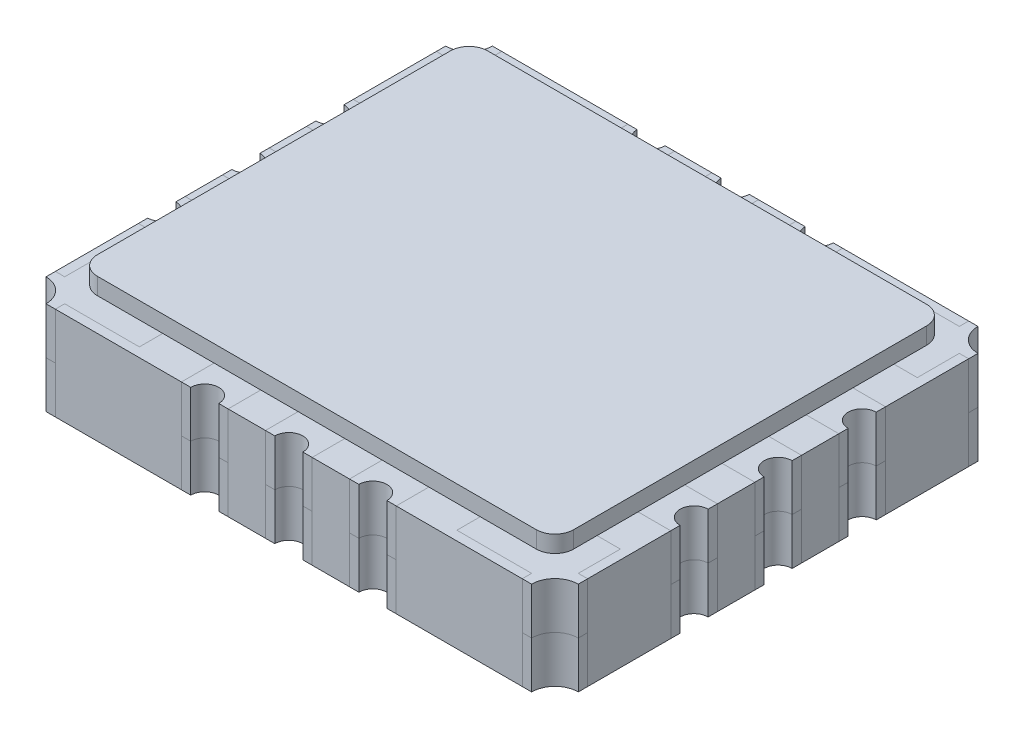
from build123d import *

# Parameters (mm, degrees)
EXTRUDE_7_DEPTH     = 0.5
EXTRUDE_7_2_DEPTH   = 0.5
EXTRUDE_7_3_DEPTH   = 0.5
EXTRUDE_7_4_DEPTH   = 0.5
EXTRUDE_7_5_DEPTH   = 0.5
EXTRUDE_7_6_DEPTH   = 0.5
EXTRUDE_7_7_DEPTH   = 0.5
EXTRUDE_7_8_DEPTH   = 0.5
EXTRUDE_7_9_DEPTH   = 0.5
EXTRUDE_7_10_DEPTH  = 0.5
EXTRUDE_7_11_DEPTH  = 0.5
EXTRUDE_7_12_DEPTH  = 0.5
EXTRUDE_7_13_DEPTH  = 0.5
EXTRUDE_7_14_DEPTH  = 0.5
EXTRUDE_7_15_DEPTH  = 0.5
EXTRUDE_7_16_DEPTH  = 0.5
EXTRUDE_7_17_DEPTH  = 0.5
EXTRUDE_10_DEPTH    = 1
EXTRUDE_START       = 0.5
EXTRUDE_11_DEPTH    = 0.5
EXTRUDE_11_2_DEPTH  = 0.5
EXTRUDE_11_3_DEPTH  = 0.5
EXTRUDE_11_4_DEPTH  = 0.5
EXTRUDE_11_5_DEPTH  = 0.5
EXTRUDE_11_6_DEPTH  = 0.5
EXTRUDE_11_7_DEPTH  = 0.5
EXTRUDE_11_8_DEPTH  = 0.5
EXTRUDE_11_9_DEPTH  = 0.5
EXTRUDE_11_10_DEPTH = 0.5
EXTRUDE_11_11_DEPTH = 0.5
EXTRUDE_11_12_DEPTH = 0.5
EXTRUDE_11_13_DEPTH = 0.5
EXTRUDE_11_14_DEPTH = 0.5
EXTRUDE_11_15_DEPTH = 0.5
EXTRUDE_11_16_DEPTH = 0.5
EXTRUDE_11_17_DEPTH = 0.5
EXTRUDE_13_DEPTH    = 1.18


with BuildPart() as part:
    # Эскиз1 → Бобышка-Вытянуть7 (new body)
    with BuildSketch(Plane(origin=(0, 0, 0), x_dir=(1, 0, 0), z_dir=(0, 1, 0))):
        with BuildLine():
            Line((-2.5, 2.39), (-2.6, 2.39))
            ThreePointArc((-2.6, 2.39), (-2.673223305, 2.213223305), (-2.85, 2.14))
            Line((-2.85, 2.14), (-2.85, 2.04))
            Line((-2.85, 2.04), (-2.75, 2.04))
            Line((-2.75, 2.04), (-2.75, 1.59))
            Line((-2.75, 1.59), (-1.7, 1.59))
            Line((-1.7, 1.59), (-1.7, 2.29))
            Line((-1.7, 2.29), (-2.5, 2.29))
            Line((-2.5, 2.29), (-2.5, 2.39))
        make_face()
    extrude(amount=EXTRUDE_7_DEPTH)


with BuildPart() as body_2:
    # Эскиз1 → Extrude 7 2 (new body)
    with BuildSketch(Plane(origin=(0, 0, 0), x_dir=(1, 0, 0), z_dir=(0, 1, 0))):
        with BuildLine():
            Line((-1.05, 2.39), (-1.15, 2.39))
            Line((-1.15, 2.39), (-1.15, 1.39))
            Line((-1.15, 1.39), (-0.65, 1.39))
            Line((-0.65, 1.39), (-0.65, 2.39))
            Line((-0.65, 2.39), (-0.75, 2.39))
            ThreePointArc((-0.75, 2.39), (-0.9, 2.24), (-1.05, 2.39))
        make_face()
    extrude(amount=EXTRUDE_7_2_DEPTH)


with BuildPart() as body_3:
    # Эскиз1 → Extrude 7 3 (new body)
    with BuildSketch(Plane(origin=(0, 0, 0), x_dir=(1, 0, 0), z_dir=(0, 1, 0))):
        with BuildLine():
            Line((-2.85, 1.15), (-2.85, 1.05))
            ThreePointArc((-2.85, 1.05), (-2.7, 0.9), (-2.85, 0.75))
            Line((-2.85, 0.75), (-2.85, 0.65))
            Line((-2.85, 0.65), (-1.85, 0.65))
            Line((-1.85, 0.65), (-1.85, 1.15))
            Line((-1.85, 1.15), (-2.85, 1.15))
        make_face()
    extrude(amount=EXTRUDE_7_3_DEPTH)


with BuildPart() as body_4:
    # Эскиз1 → Extrude 7 4 (new body)
    with BuildSketch(Plane(origin=(0, 0, 0), x_dir=(1, 0, 0), z_dir=(0, 1, 0))):
        with BuildLine():
            Line((0.25, 1.39), (0.25, 2.39))
            Line((0.25, 2.39), (0.15, 2.39))
            ThreePointArc((0.15, 2.39), (0, 2.24), (-0.15, 2.39))
            Line((-0.15, 2.39), (-0.25, 2.39))
            Line((-0.25, 2.39), (-0.25, 1.39))
            Line((-0.25, 1.39), (0.25, 1.39))
        make_face()
    extrude(amount=EXTRUDE_7_4_DEPTH)


with BuildPart() as body_5:
    # Эскиз1 → Extrude 7 5 (new body)
    with BuildSketch(Plane(origin=(0, 0, 0), x_dir=(1, 0, 0), z_dir=(0, 1, 0))):
        with BuildLine():
            Line((-2.85, -0.25), (-1.85, -0.25))
            Line((-1.85, -0.25), (-1.85, 0.25))
            Line((-1.85, 0.25), (-2.85, 0.25))
            Line((-2.85, 0.25), (-2.85, 0.15))
            ThreePointArc((-2.85, 0.15), (-2.7, 0), (-2.85, -0.15))
            Line((-2.85, -0.15), (-2.85, -0.25))
        make_face()
    extrude(amount=EXTRUDE_7_5_DEPTH)


with BuildPart() as body_6:
    # Эскиз1 → Extrude 7 6 (new body)
    with BuildSketch(Plane(origin=(0, 0, 0), x_dir=(1, 0, 0), z_dir=(0, 1, 0))):
        with BuildLine():
            Line((1.15, 1.39), (1.15, 2.39))
            Line((1.15, 2.39), (1.05, 2.39))
            ThreePointArc((1.05, 2.39), (0.9, 2.24), (0.75, 2.39))
            Line((0.75, 2.39), (0.65, 2.39))
            Line((0.65, 2.39), (0.65, 1.39))
            Line((0.65, 1.39), (1.15, 1.39))
        make_face()
    extrude(amount=EXTRUDE_7_6_DEPTH)


with BuildPart() as body_7:
    # Эскиз1 → Extrude 7 7 (new body)
    with BuildSketch(Plane(origin=(0, 0, 0), x_dir=(1, 0, 0), z_dir=(0, 1, 0))):
        with BuildLine():
            Line((-2.85, -1.15), (-1.85, -1.15))
            Line((-1.85, -1.15), (-1.85, -0.65))
            Line((-1.85, -0.65), (-2.85, -0.65))
            Line((-2.85, -0.65), (-2.85, -0.75))
            ThreePointArc((-2.85, -0.75), (-2.7, -0.9), (-2.85, -1.05))
            Line((-2.85, -1.05), (-2.85, -1.15))
        make_face()
    extrude(amount=EXTRUDE_7_7_DEPTH)


with BuildPart() as body_8:
    # Эскиз1 → Extrude 7 8 (new body)
    with BuildSketch(Plane(origin=(0, 0, 0), x_dir=(1, 0, 0), z_dir=(0, 1, 0))):
        with BuildLine():
            Line((1.7, 1.59), (2.75, 1.59))
            Line((2.75, 1.59), (2.75, 2.04))
            Line((2.75, 2.04), (2.85, 2.04))
            Line((2.85, 2.04), (2.85, 2.14))
            ThreePointArc((2.85, 2.14), (2.673223305, 2.213223305), (2.6, 2.39))
            Line((2.6, 2.39), (2.5, 2.39))
            Line((2.5, 2.39), (2.5, 2.29))
            Line((2.5, 2.29), (1.7, 2.29))
            Line((1.7, 2.29), (1.7, 1.59))
        make_face()
    extrude(amount=EXTRUDE_7_8_DEPTH)


with BuildPart() as body_9:
    # Эскиз1 → Extrude 7 9 (new body)
    with BuildSketch(Plane(origin=(0, 0, 0), x_dir=(1, 0, 0), z_dir=(0, 1, 0))):
        with BuildLine():
            Line((-1.7, -2.29), (-1.7, -1.59))
            Line((-1.7, -1.59), (-2.75, -1.59))
            Line((-2.75, -1.59), (-2.75, -2.04))
            Line((-2.75, -2.04), (-2.85, -2.04))
            Line((-2.85, -2.04), (-2.85, -2.14))
            ThreePointArc((-2.85, -2.14), (-2.673223305, -2.213223305), (-2.6, -2.39))
            Line((-2.6, -2.39), (-2.5, -2.39))
            Line((-2.5, -2.39), (-2.5, -2.29))
            Line((-2.5, -2.29), (-1.7, -2.29))
        make_face()
    extrude(amount=EXTRUDE_7_9_DEPTH)


with BuildPart() as body_10:
    # Эскиз1 → Extrude 7 10 (new body)
    with BuildSketch(Plane(origin=(0, 0, 0), x_dir=(1, 0, 0), z_dir=(0, 1, 0))):
        with BuildLine():
            Line((1.85, 0.65), (2.85, 0.65))
            Line((2.85, 0.65), (2.85, 0.75))
            ThreePointArc((2.85, 0.75), (2.7, 0.9), (2.85, 1.05))
            Line((2.85, 1.05), (2.85, 1.15))
            Line((2.85, 1.15), (1.85, 1.15))
            Line((1.85, 1.15), (1.85, 0.65))
        make_face()
    extrude(amount=EXTRUDE_7_10_DEPTH)


with BuildPart() as body_11:
    # Эскиз1 → Extrude 7 11 (new body)
    with BuildSketch(Plane(origin=(0, 0, 0), x_dir=(1, 0, 0), z_dir=(0, 1, 0))):
        with BuildLine():
            Line((-0.65, -2.39), (-0.65, -1.39))
            Line((-0.65, -1.39), (-1.15, -1.39))
            Line((-1.15, -1.39), (-1.15, -2.39))
            Line((-1.15, -2.39), (-1.05, -2.39))
            ThreePointArc((-1.05, -2.39), (-0.9, -2.24), (-0.75, -2.39))
            Line((-0.75, -2.39), (-0.65, -2.39))
        make_face()
    extrude(amount=EXTRUDE_7_11_DEPTH)


with BuildPart() as body_12:
    # Эскиз1 → Extrude 7 12 (new body)
    with BuildSketch(Plane(origin=(0, 0, 0), x_dir=(1, 0, 0), z_dir=(0, 1, 0))):
        with BuildLine():
            Line((1.85, -0.25), (2.85, -0.25))
            Line((2.85, -0.25), (2.85, -0.15))
            ThreePointArc((2.85, -0.15), (2.7, 0), (2.85, 0.15))
            Line((2.85, 0.15), (2.85, 0.25))
            Line((2.85, 0.25), (1.85, 0.25))
            Line((1.85, 0.25), (1.85, -0.25))
        make_face()
    extrude(amount=EXTRUDE_7_12_DEPTH)


with BuildPart() as body_13:
    # Эскиз1 → Extrude 7 13 (new body)
    with BuildSketch(Plane(origin=(0, 0, 0), x_dir=(1, 0, 0), z_dir=(0, 1, 0))):
        with BuildLine():
            Line((0.25, -2.39), (0.25, -1.39))
            Line((0.25, -1.39), (-0.25, -1.39))
            Line((-0.25, -1.39), (-0.25, -2.39))
            Line((-0.25, -2.39), (-0.15, -2.39))
            ThreePointArc((-0.15, -2.39), (0, -2.24), (0.15, -2.39))
            Line((0.15, -2.39), (0.25, -2.39))
        make_face()
    extrude(amount=EXTRUDE_7_13_DEPTH)


with BuildPart() as body_14:
    # Эскиз1 → Extrude 7 14 (new body)
    with BuildSketch(Plane(origin=(0, 0, 0), x_dir=(1, 0, 0), z_dir=(0, 1, 0))):
        with BuildLine():
            Line((1.85, -1.15), (2.85, -1.15))
            Line((2.85, -1.15), (2.85, -1.05))
            ThreePointArc((2.85, -1.05), (2.7, -0.9), (2.85, -0.75))
            Line((2.85, -0.75), (2.85, -0.65))
            Line((2.85, -0.65), (1.85, -0.65))
            Line((1.85, -0.65), (1.85, -1.15))
        make_face()
    extrude(amount=EXTRUDE_7_14_DEPTH)


with BuildPart() as body_15:
    # Эскиз1 → Extrude 7 15 (new body)
    with BuildSketch(Plane(origin=(0, 0, 0), x_dir=(1, 0, 0), z_dir=(0, 1, 0))):
        with BuildLine():
            Line((1.15, -2.39), (1.15, -1.39))
            Line((1.15, -1.39), (0.65, -1.39))
            Line((0.65, -1.39), (0.65, -2.39))
            Line((0.65, -2.39), (0.75, -2.39))
            ThreePointArc((0.75, -2.39), (0.9, -2.24), (1.05, -2.39))
            Line((1.05, -2.39), (1.15, -2.39))
        make_face()
    extrude(amount=EXTRUDE_7_15_DEPTH)


with BuildPart() as body_16:
    # Эскиз1 → Extrude 7 16 (new body)
    with BuildSketch(Plane(origin=(0, 0, 0), x_dir=(1, 0, 0), z_dir=(0, 1, 0))):
        with BuildLine():
            Line((1.7, -1.59), (1.7, -2.29))
            Line((1.7, -2.29), (2.5, -2.29))
            Line((2.5, -2.29), (2.5, -2.39))
            Line((2.5, -2.39), (2.6, -2.39))
            ThreePointArc((2.6, -2.39), (2.673223305, -2.213223305), (2.85, -2.14))
            Line((2.85, -2.14), (2.85, -2.04))
            Line((2.85, -2.04), (2.75, -2.04))
            Line((2.75, -2.04), (2.75, -1.59))
            Line((2.75, -1.59), (1.7, -1.59))
        make_face()
    extrude(amount=EXTRUDE_7_16_DEPTH)


with BuildPart() as body_17:
    # Эскиз1 → Extrude 7 17 (new body)
    with BuildSketch(Plane(origin=(0, 0, 0), x_dir=(1, 0, 0), z_dir=(0, 1, 0))):
        Polygon((-0.722867966, 0.935), (-0.935, 0.722867966), (-0.935, -0.935), (0.935, -0.935), (0.935, 0.935), align=None)
    extrude(amount=EXTRUDE_7_17_DEPTH)


with BuildPart() as body_18:
    # Эскиз1<13> → Бобышка-Вытянуть10 (new body)
    with BuildSketch(Plane(origin=(0, 0, 0), x_dir=(1, 0, 0), z_dir=(0, 1, 0))):
        Polygon((-1.15, 2.39), (-2.5, 2.39), (-2.5, 2.29), (-1.7, 2.29), (-1.7, 1.59), (-2.75, 1.59), (-2.75, 2.04), (-2.85, 2.04), (-2.85, 1.15), (-1.85, 1.15), (-1.85, 0.65), (-2.85, 0.65), (-2.85, 0.25), (-1.85, 0.25), (-1.85, -0.25), (-2.85, -0.25), (-2.85, -0.65), (-1.85, -0.65), (-1.85, -1.15), (-2.85, -1.15), (-2.85, -2.04), (-2.75, -2.04), (-2.75, -1.59), (-1.7, -1.59), (-1.7, -2.29), (-2.5, -2.29), (-2.5, -2.39), (-1.15, -2.39), (-1.15, -1.39), (-0.65, -1.39), (-0.65, -2.39), (-0.25, -2.39), (-0.25, -1.39), (0.25, -1.39), (0.25, -2.39), (0.65, -2.39), (0.65, -1.39), (1.15, -1.39), (1.15, -2.39), (2.5, -2.39), (2.5, -2.29), (1.7, -2.29), (1.7, -1.59), (2.75, -1.59), (2.75, -2.04), (2.85, -2.04), (2.85, -1.15), (1.85, -1.15), (1.85, -0.65), (2.85, -0.65), (2.85, -0.25), (1.85, -0.25), (1.85, 0.25), (2.85, 0.25), (2.85, 0.65), (1.85, 0.65), (1.85, 1.15), (2.85, 1.15), (2.85, 2.04), (2.75, 2.04), (2.75, 1.59), (1.7, 1.59), (1.7, 2.29), (2.5, 2.29), (2.5, 2.39), (1.15, 2.39), (1.15, 1.39), (0.65, 1.39), (0.65, 2.39), (0.25, 2.39), (0.25, 1.39), (-0.25, 1.39), (-0.25, 2.39), (-0.65, 2.39), (-0.65, 1.39), (-1.15, 1.39), align=None)
        Polygon((-0.935, 0.722867966), (-0.722867966, 0.935), (0.935, 0.935), (0.935, -0.935), (-0.935, -0.935), align=None, mode=Mode.SUBTRACT)
    extrude(amount=EXTRUDE_10_DEPTH)


with BuildPart() as body_19:
    # Эскиз1<14> → Бобышка-Вытянуть11 (new body)
    with BuildSketch(Plane(origin=(0, 0, 0), x_dir=(1, 0, 0), z_dir=(0, 1, 0)).offset(EXTRUDE_START)):
        with BuildLine():
            Line((-2.5, 2.39), (-2.6, 2.39))
            ThreePointArc((-2.6, 2.39), (-2.673223305, 2.213223305), (-2.85, 2.14))
            Line((-2.85, 2.14), (-2.85, 2.04))
            Line((-2.85, 2.04), (-2.75, 2.04))
            Line((-2.75, 2.04), (-2.75, 1.59))
            Line((-2.75, 1.59), (-1.7, 1.59))
            Line((-1.7, 1.59), (-1.7, 2.29))
            Line((-1.7, 2.29), (-2.5, 2.29))
            Line((-2.5, 2.29), (-2.5, 2.39))
        make_face()
    extrude(amount=EXTRUDE_11_DEPTH)


with BuildPart() as body_20:
    # Эскиз1<14> → Extrude 11 2 (new body)
    with BuildSketch(Plane(origin=(0, 0, 0), x_dir=(1, 0, 0), z_dir=(0, 1, 0)).offset(EXTRUDE_START)):
        with BuildLine():
            Line((-1.05, 2.39), (-1.15, 2.39))
            Line((-1.15, 2.39), (-1.15, 1.39))
            Line((-1.15, 1.39), (-0.65, 1.39))
            Line((-0.65, 1.39), (-0.65, 2.39))
            Line((-0.65, 2.39), (-0.75, 2.39))
            ThreePointArc((-0.75, 2.39), (-0.9, 2.24), (-1.05, 2.39))
        make_face()
    extrude(amount=EXTRUDE_11_2_DEPTH)


with BuildPart() as body_21:
    # Эскиз1<14> → Extrude 11 3 (new body)
    with BuildSketch(Plane(origin=(0, 0, 0), x_dir=(1, 0, 0), z_dir=(0, 1, 0)).offset(EXTRUDE_START)):
        with BuildLine():
            Line((-2.85, 1.15), (-2.85, 1.05))
            ThreePointArc((-2.85, 1.05), (-2.7, 0.9), (-2.85, 0.75))
            Line((-2.85, 0.75), (-2.85, 0.65))
            Line((-2.85, 0.65), (-1.85, 0.65))
            Line((-1.85, 0.65), (-1.85, 1.15))
            Line((-1.85, 1.15), (-2.85, 1.15))
        make_face()
    extrude(amount=EXTRUDE_11_3_DEPTH)


with BuildPart() as body_22:
    # Эскиз1<14> → Extrude 11 4 (new body)
    with BuildSketch(Plane(origin=(0, 0, 0), x_dir=(1, 0, 0), z_dir=(0, 1, 0)).offset(EXTRUDE_START)):
        with BuildLine():
            Line((0.25, 1.39), (0.25, 2.39))
            Line((0.25, 2.39), (0.15, 2.39))
            ThreePointArc((0.15, 2.39), (0, 2.24), (-0.15, 2.39))
            Line((-0.15, 2.39), (-0.25, 2.39))
            Line((-0.25, 2.39), (-0.25, 1.39))
            Line((-0.25, 1.39), (0.25, 1.39))
        make_face()
    extrude(amount=EXTRUDE_11_4_DEPTH)


with BuildPart() as body_23:
    # Эскиз1<14> → Extrude 11 5 (new body)
    with BuildSketch(Plane(origin=(0, 0, 0), x_dir=(1, 0, 0), z_dir=(0, 1, 0)).offset(EXTRUDE_START)):
        with BuildLine():
            Line((-2.85, -0.25), (-1.85, -0.25))
            Line((-1.85, -0.25), (-1.85, 0.25))
            Line((-1.85, 0.25), (-2.85, 0.25))
            Line((-2.85, 0.25), (-2.85, 0.15))
            ThreePointArc((-2.85, 0.15), (-2.7, 0), (-2.85, -0.15))
            Line((-2.85, -0.15), (-2.85, -0.25))
        make_face()
    extrude(amount=EXTRUDE_11_5_DEPTH)


with BuildPart() as body_24:
    # Эскиз1<14> → Extrude 11 6 (new body)
    with BuildSketch(Plane(origin=(0, 0, 0), x_dir=(1, 0, 0), z_dir=(0, 1, 0)).offset(EXTRUDE_START)):
        with BuildLine():
            Line((1.15, 1.39), (1.15, 2.39))
            Line((1.15, 2.39), (1.05, 2.39))
            ThreePointArc((1.05, 2.39), (0.9, 2.24), (0.75, 2.39))
            Line((0.75, 2.39), (0.65, 2.39))
            Line((0.65, 2.39), (0.65, 1.39))
            Line((0.65, 1.39), (1.15, 1.39))
        make_face()
    extrude(amount=EXTRUDE_11_6_DEPTH)


with BuildPart() as body_25:
    # Эскиз1<14> → Extrude 11 7 (new body)
    with BuildSketch(Plane(origin=(0, 0, 0), x_dir=(1, 0, 0), z_dir=(0, 1, 0)).offset(EXTRUDE_START)):
        with BuildLine():
            Line((-2.85, -1.15), (-1.85, -1.15))
            Line((-1.85, -1.15), (-1.85, -0.65))
            Line((-1.85, -0.65), (-2.85, -0.65))
            Line((-2.85, -0.65), (-2.85, -0.75))
            ThreePointArc((-2.85, -0.75), (-2.7, -0.9), (-2.85, -1.05))
            Line((-2.85, -1.05), (-2.85, -1.15))
        make_face()
    extrude(amount=EXTRUDE_11_7_DEPTH)


with BuildPart() as body_26:
    # Эскиз1<14> → Extrude 11 8 (new body)
    with BuildSketch(Plane(origin=(0, 0, 0), x_dir=(1, 0, 0), z_dir=(0, 1, 0)).offset(EXTRUDE_START)):
        with BuildLine():
            Line((1.7, 1.59), (2.75, 1.59))
            Line((2.75, 1.59), (2.75, 2.04))
            Line((2.75, 2.04), (2.85, 2.04))
            Line((2.85, 2.04), (2.85, 2.14))
            ThreePointArc((2.85, 2.14), (2.673223305, 2.213223305), (2.6, 2.39))
            Line((2.6, 2.39), (2.5, 2.39))
            Line((2.5, 2.39), (2.5, 2.29))
            Line((2.5, 2.29), (1.7, 2.29))
            Line((1.7, 2.29), (1.7, 1.59))
        make_face()
    extrude(amount=EXTRUDE_11_8_DEPTH)


with BuildPart() as body_27:
    # Эскиз1<14> → Extrude 11 9 (new body)
    with BuildSketch(Plane(origin=(0, 0, 0), x_dir=(1, 0, 0), z_dir=(0, 1, 0)).offset(EXTRUDE_START)):
        with BuildLine():
            Line((-1.7, -2.29), (-1.7, -1.59))
            Line((-1.7, -1.59), (-2.75, -1.59))
            Line((-2.75, -1.59), (-2.75, -2.04))
            Line((-2.75, -2.04), (-2.85, -2.04))
            Line((-2.85, -2.04), (-2.85, -2.14))
            ThreePointArc((-2.85, -2.14), (-2.673223305, -2.213223305), (-2.6, -2.39))
            Line((-2.6, -2.39), (-2.5, -2.39))
            Line((-2.5, -2.39), (-2.5, -2.29))
            Line((-2.5, -2.29), (-1.7, -2.29))
        make_face()
    extrude(amount=EXTRUDE_11_9_DEPTH)


with BuildPart() as body_28:
    # Эскиз1<14> → Extrude 11 10 (new body)
    with BuildSketch(Plane(origin=(0, 0, 0), x_dir=(1, 0, 0), z_dir=(0, 1, 0)).offset(EXTRUDE_START)):
        with BuildLine():
            Line((1.85, 0.65), (2.85, 0.65))
            Line((2.85, 0.65), (2.85, 0.75))
            ThreePointArc((2.85, 0.75), (2.7, 0.9), (2.85, 1.05))
            Line((2.85, 1.05), (2.85, 1.15))
            Line((2.85, 1.15), (1.85, 1.15))
            Line((1.85, 1.15), (1.85, 0.65))
        make_face()
    extrude(amount=EXTRUDE_11_10_DEPTH)


with BuildPart() as body_29:
    # Эскиз1<14> → Extrude 11 11 (new body)
    with BuildSketch(Plane(origin=(0, 0, 0), x_dir=(1, 0, 0), z_dir=(0, 1, 0)).offset(EXTRUDE_START)):
        with BuildLine():
            Line((-0.65, -2.39), (-0.65, -1.39))
            Line((-0.65, -1.39), (-1.15, -1.39))
            Line((-1.15, -1.39), (-1.15, -2.39))
            Line((-1.15, -2.39), (-1.05, -2.39))
            ThreePointArc((-1.05, -2.39), (-0.9, -2.24), (-0.75, -2.39))
            Line((-0.75, -2.39), (-0.65, -2.39))
        make_face()
    extrude(amount=EXTRUDE_11_11_DEPTH)


with BuildPart() as body_30:
    # Эскиз1<14> → Extrude 11 12 (new body)
    with BuildSketch(Plane(origin=(0, 0, 0), x_dir=(1, 0, 0), z_dir=(0, 1, 0)).offset(EXTRUDE_START)):
        with BuildLine():
            Line((1.85, -0.25), (2.85, -0.25))
            Line((2.85, -0.25), (2.85, -0.15))
            ThreePointArc((2.85, -0.15), (2.7, 0), (2.85, 0.15))
            Line((2.85, 0.15), (2.85, 0.25))
            Line((2.85, 0.25), (1.85, 0.25))
            Line((1.85, 0.25), (1.85, -0.25))
        make_face()
    extrude(amount=EXTRUDE_11_12_DEPTH)


with BuildPart() as body_31:
    # Эскиз1<14> → Extrude 11 13 (new body)
    with BuildSketch(Plane(origin=(0, 0, 0), x_dir=(1, 0, 0), z_dir=(0, 1, 0)).offset(EXTRUDE_START)):
        with BuildLine():
            Line((0.25, -2.39), (0.25, -1.39))
            Line((0.25, -1.39), (-0.25, -1.39))
            Line((-0.25, -1.39), (-0.25, -2.39))
            Line((-0.25, -2.39), (-0.15, -2.39))
            ThreePointArc((-0.15, -2.39), (0, -2.24), (0.15, -2.39))
            Line((0.15, -2.39), (0.25, -2.39))
        make_face()
    extrude(amount=EXTRUDE_11_13_DEPTH)


with BuildPart() as body_32:
    # Эскиз1<14> → Extrude 11 14 (new body)
    with BuildSketch(Plane(origin=(0, 0, 0), x_dir=(1, 0, 0), z_dir=(0, 1, 0)).offset(EXTRUDE_START)):
        with BuildLine():
            Line((1.85, -1.15), (2.85, -1.15))
            Line((2.85, -1.15), (2.85, -1.05))
            ThreePointArc((2.85, -1.05), (2.7, -0.9), (2.85, -0.75))
            Line((2.85, -0.75), (2.85, -0.65))
            Line((2.85, -0.65), (1.85, -0.65))
            Line((1.85, -0.65), (1.85, -1.15))
        make_face()
    extrude(amount=EXTRUDE_11_14_DEPTH)


with BuildPart() as body_33:
    # Эскиз1<14> → Extrude 11 15 (new body)
    with BuildSketch(Plane(origin=(0, 0, 0), x_dir=(1, 0, 0), z_dir=(0, 1, 0)).offset(EXTRUDE_START)):
        with BuildLine():
            Line((1.15, -2.39), (1.15, -1.39))
            Line((1.15, -1.39), (0.65, -1.39))
            Line((0.65, -1.39), (0.65, -2.39))
            Line((0.65, -2.39), (0.75, -2.39))
            ThreePointArc((0.75, -2.39), (0.9, -2.24), (1.05, -2.39))
            Line((1.05, -2.39), (1.15, -2.39))
        make_face()
    extrude(amount=EXTRUDE_11_15_DEPTH)


with BuildPart() as body_34:
    # Эскиз1<14> → Extrude 11 16 (new body)
    with BuildSketch(Plane(origin=(0, 0, 0), x_dir=(1, 0, 0), z_dir=(0, 1, 0)).offset(EXTRUDE_START)):
        with BuildLine():
            Line((1.7, -1.59), (1.7, -2.29))
            Line((1.7, -2.29), (2.5, -2.29))
            Line((2.5, -2.29), (2.5, -2.39))
            Line((2.5, -2.39), (2.6, -2.39))
            ThreePointArc((2.6, -2.39), (2.673223305, -2.213223305), (2.85, -2.14))
            Line((2.85, -2.14), (2.85, -2.04))
            Line((2.85, -2.04), (2.75, -2.04))
            Line((2.75, -2.04), (2.75, -1.59))
            Line((2.75, -1.59), (1.7, -1.59))
        make_face()
    extrude(amount=EXTRUDE_11_16_DEPTH)


with BuildPart() as body_35:
    # Эскиз1<14> → Extrude 11 17 (new body)
    with BuildSketch(Plane(origin=(0, 0, 0), x_dir=(1, 0, 0), z_dir=(0, 1, 0)).offset(EXTRUDE_START)):
        Polygon((-0.722867966, 0.935), (-0.935, 0.722867966), (-0.935, -0.935), (0.935, -0.935), (0.935, 0.935), align=None)
    extrude(amount=EXTRUDE_11_17_DEPTH)


with BuildPart() as body_36:
    # Эскиз1<16> → Бобышка-Вытянуть13 (new body)
    with BuildSketch(Plane(origin=(0, 0, 0), x_dir=(1, 0, 0), z_dir=(0, 1, 0))):
        with BuildLine():
            Line((-2.4, 2.14), (2.3, 2.14))
            ThreePointArc((2.3, 2.14), (2.441421356, 2.081421356), (2.5, 1.94))
            Line((2.5, 1.94), (2.5, -1.84))
            ThreePointArc((2.5, -1.84), (2.441421356, -1.981421356), (2.3, -2.04))
            Line((2.3, -2.04), (-2.4, -2.04))
            ThreePointArc((-2.4, -2.04), (-2.541421356, -1.981421356), (-2.6, -1.84))
            Line((-2.6, -1.84), (-2.6, 1.94))
            ThreePointArc((-2.6, 1.94), (-2.541421356, 2.081421356), (-2.4, 2.14))
        make_face()
    extrude(amount=EXTRUDE_13_DEPTH)


solid = Compound([part.part, body_2.part, body_3.part, body_4.part, body_5.part, body_6.part, body_7.part, body_8.part, body_9.part, body_10.part, body_11.part, body_12.part, body_13.part, body_14.part, body_15.part, body_16.part, body_17.part, body_18.part, body_19.part, body_20.part, body_21.part, body_22.part, body_23.part, body_24.part, body_25.part, body_26.part, body_27.part, body_28.part, body_29.part, body_30.part, body_31.part, body_32.part, body_33.part, body_34.part, body_35.part, body_36.part])
